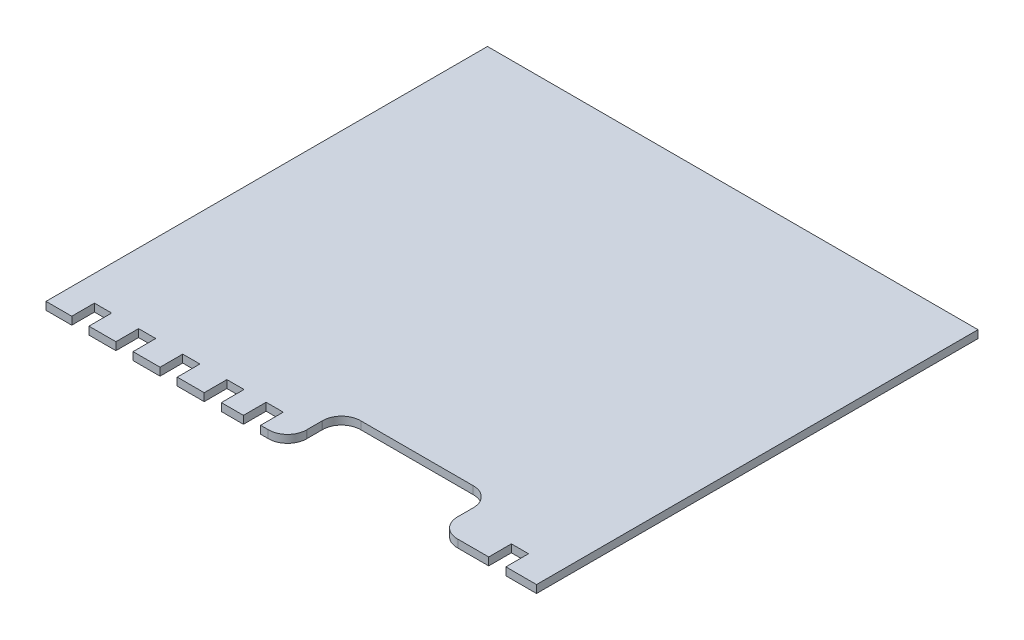
from build123d import *

# Parameters (mm, degrees)
BOSS_EXTRUDE1_DEPTH = 1.5875


with BuildPart() as part:
    # Sketch1 → Boss-Extrude1 (new body)
    with BuildSketch(Plane(origin=(0, 0, 0), x_dir=(1, 0, 0), z_dir=(0, 1, 0))):
        with BuildLine():
            Line((0, 90), (100, 90))
            Line((100, 90), (100, 0))
            Line((100, 0), (93.75, 0))
            Line((93.75, 0), (93.75, 4.625))
            Line((93.75, 4.625), (90.25, 4.625))
            Line((90.25, 4.625), (90.25, 0))
            Line((90.25, 0), (84, 0))
            ThreePointArc((84, 0), (81.178095625, 1.089694192), (79.99799, 3.875))
            Line((79.99799, 3.875), (80, 4))
            Line((80, 4), (80, 7))
            Line((80, 7), (80.00201, 7.125))
            ThreePointArc((80.00201, 7.125), (78.821904375, 9.910305808), (76, 11))
            Line((76, 11), (53.25, 11))
            ThreePointArc((53.25, 11), (50.428095625, 9.910305808), (49.24799, 7.125))
            Line((49.24799, 7.125), (49.25, 7))
            Line((49.25, 7), (49.25, 4))
            Line((49.25, 4), (49.25201, 3.87502))
            ThreePointArc((49.25201, 3.87502), (48.071906674, 1.089706193), (45.25, 0))
            Line((45.25, 0), (43.75, 0))
            Line((43.75, 0), (43.75, 4.625))
            Line((43.75, 4.625), (40.25, 4.625))
            Line((40.25, 4.625), (40.25, 0))
            Line((40.25, 0), (35.75, 0))
            Line((35.75, 0), (35.75, 4.625))
            Line((35.75, 4.625), (32.25, 4.625))
            Line((32.25, 4.625), (32.25, 0))
            Line((32.25, 0), (26.75, 0))
            Line((26.75, 0), (26.75, 4.625))
            Line((26.75, 4.625), (23.25, 4.625))
            Line((23.25, 4.625), (23.25, 0))
            Line((23.25, 0), (17.75, 0))
            Line((17.75, 0), (17.75, 4.625))
            Line((17.75, 4.625), (14.25, 4.625))
            Line((14.25, 4.625), (14.25, 0))
            Line((14.25, 0), (8.75, 0))
            Line((8.75, 0), (8.75, 4.625))
            Line((8.75, 4.625), (5.25, 4.625))
            Line((5.25, 4.625), (5.25, 0))
            Line((5.25, 0), (0, 0))
            Line((0, 0), (0, 90))
        make_face()
    extrude(amount=BOSS_EXTRUDE1_DEPTH)


solid = part.part
